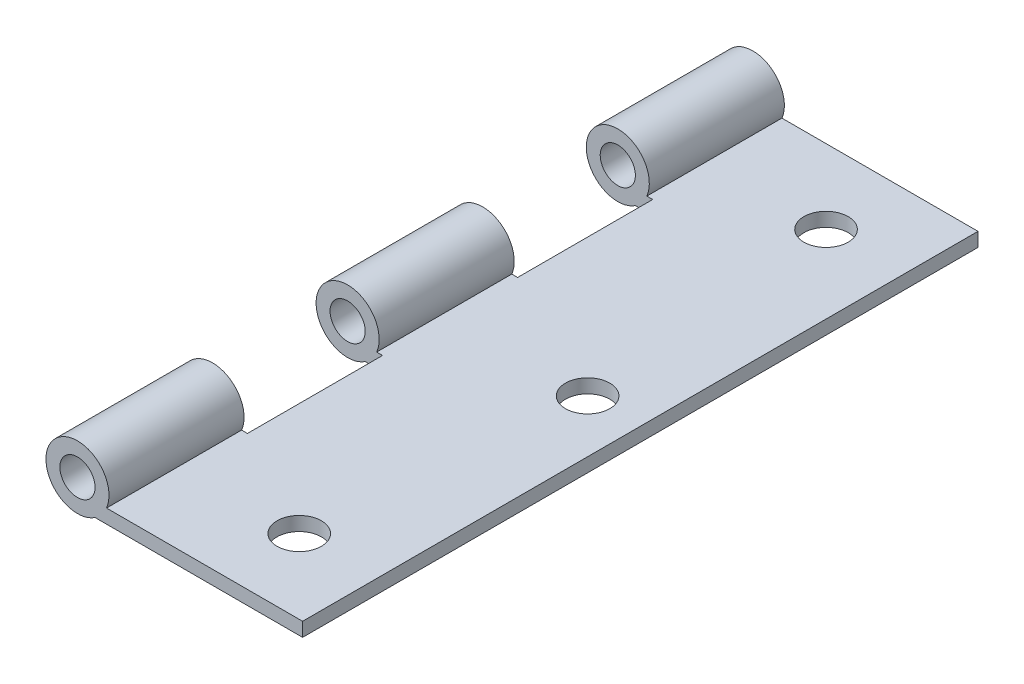
from build123d import *

# Parameters (mm, degrees)
BOSS_EXTRUDE1_DEPTH                            = 76.2
CUT_EXTRUDE1_DEPTH                             = 15.24
CUT_EXTRUDE2_DEPTH                             = 15.24
CSK_FOR_M3_FLAT_HEAD_MACHINE_SCREW1_AT_2_COUNT = 2
CSK_FOR_M3_FLAT_HEAD_MACHINE_SCREW1_AT_2_PITCH = 59.436
CSK_FOR_M3_FLAT_HEAD_MACHINE_SCREW1_AT_3_COUNT = 2
CSK_FOR_M3_FLAT_HEAD_MACHINE_SCREW1_AT_3_PITCH = 29.851441177
M3_5_CLEARANCE_HOLE1_D                         = 3.96875
M3_5_CLEARANCE_HOLE1_DEPTH                     = 15.24
M3_5_CLEARANCE_HOLE2_D                         = 3.96875
M3_5_CLEARANCE_HOLE2_DEPTH                     = 15.24
M3_5_CLEARANCE_HOLE3_D                         = 3.96875
M3_5_CLEARANCE_HOLE3_DEPTH                     = 45.72
SKETCH21_R                                     = 2.5
CUT_EXTRUDE3_DEPTH                             = 1.5748


with BuildPart() as part:
    # Sketch1 → Boss-Extrude1 (new body)
    with BuildSketch(Plane.XY.offset(38.1)):
        with BuildLine():
            Line((25.4, -2.950829012), (25.4, -1.376029012))
            Line((25.4, -1.376029012), (3.278975474, -1.376029012))
            ThreePointArc((3.278975474, -1.376029012), (-2.746946179, 2.258190135), (1.984375, -2.950829012))
            Line((1.984375, -2.950829012), (25.4, -2.950829012))
        make_face()
    extrude(amount=-BOSS_EXTRUDE1_DEPTH)

    # Sketch6 → Cut-Extrude1 (cut)
    with BuildSketch(Plane(origin=(0, 0, -22.86), x_dir=(-1, 0, 0), z_dir=(0, 0, -1))):
        with BuildLine():
            Line((-3.937, -1.376029012), (-3.937, -2.950829012))
            Line((-3.937, -2.950829012), (-1.984375, -2.950829012))
            ThreePointArc((-1.984375, -2.950829012), (2.746946179, 2.258190135), (-3.278975474, -1.376029012))
            Line((-3.278975474, -1.376029012), (-3.937, -1.376029012))
        make_face()
    extrude(amount=-CUT_EXTRUDE1_DEPTH, mode=Mode.SUBTRACT)

    # Sketch12 → Cut-Extrude2 (cut)
    with BuildSketch(Plane(origin=(0, 0, 7.62), x_dir=(-1, 0, 0), z_dir=(0, 0, -1))):
        with BuildLine():
            Line((-3.937, -1.376029012), (-3.937, -2.950829012))
            Line((-3.937, -2.950829012), (-1.984375, -2.950829012))
            ThreePointArc((-1.984375, -2.950829012), (2.746946179, 2.258190135), (-3.278975474, -1.376029012))
            Line((-3.278975474, -1.376029012), (-3.937, -1.376029012))
        make_face()
    extrude(amount=-CUT_EXTRUDE2_DEPTH, mode=Mode.SUBTRACT)

    # Sketch13 → CSK for M3 Flat Head Machine Screw1 (revolve, cut)
    with BuildSketch(Plane(origin=(16.637, -1.376029012, -29.718), x_dir=(0, 0, 1), z_dir=(1, 0, 0))):
        Polygon((0, 0), (0, 2.179970988), (1.7526, 2.179970988), (1.7526, 0.7874), (2.437076377, 0), align=None)
    csk_for_m3_flat_head_machine_screw1 = revolve(axis=Axis((16.637, 4.973970988, -29.718), (0, -1, 0)), mode=Mode.SUBTRACT)

    # CSK for M3 Flat Head Machine Screw1 at 2: CSK for M3 Flat Head Machine Screw1 ×2
    with Locations(*[(0, 0, i * CSK_FOR_M3_FLAT_HEAD_MACHINE_SCREW1_AT_2_PITCH) for i in range(1, CSK_FOR_M3_FLAT_HEAD_MACHINE_SCREW1_AT_2_COUNT)]):
        add(csk_for_m3_flat_head_machine_screw1, mode=Mode.SUBTRACT)

    # CSK for M3 Flat Head Machine Screw1 at 3: CSK for M3 Flat Head Machine Screw1 ×2
    with Locations(*[Vector(0.094447701, 0, 0.995529825) * (i * CSK_FOR_M3_FLAT_HEAD_MACHINE_SCREW1_AT_3_PITCH) for i in range(1, CSK_FOR_M3_FLAT_HEAD_MACHINE_SCREW1_AT_3_COUNT)]):
        add(csk_for_m3_flat_head_machine_screw1, mode=Mode.SUBTRACT)

    # M3.5 Clearance Hole1
    with Locations(Plane.XY.offset(38.1)):
        with Locations((0, 0)):
            Hole(M3_5_CLEARANCE_HOLE1_D / 2, depth=M3_5_CLEARANCE_HOLE1_DEPTH)

    # M3.5 Clearance Hole2
    with Locations(Plane(origin=(0, 0, -38.1), x_dir=(-1, 0, 0), z_dir=(0, 0, -1))):
        with Locations((0, 0)):
            Hole(M3_5_CLEARANCE_HOLE2_D / 2, depth=M3_5_CLEARANCE_HOLE2_DEPTH)

    # M3.5 Clearance Hole3
    with Locations(Plane(origin=(0, 0, -7.62), x_dir=(-1, 0, 0), z_dir=(0, 0, -1))):
        with Locations((0, 0)):
            Hole(M3_5_CLEARANCE_HOLE3_D / 2, depth=M3_5_CLEARANCE_HOLE3_DEPTH)

    # Sketch21 → Cut-Extrude3 (cut)
    with BuildSketch(Plane(origin=(0, -1.376029012, 0), x_dir=(1, 0, 0), z_dir=(0, 1, 0))):
        with Locations((16.637, 29.718)):
            Circle(SKETCH21_R)
        with Locations((19.4564, 0)):
            Circle(SKETCH21_R)
        with Locations((16.637, -29.718)):
            Circle(SKETCH21_R)
    extrude(amount=-CUT_EXTRUDE3_DEPTH, mode=Mode.SUBTRACT)


solid = part.part
